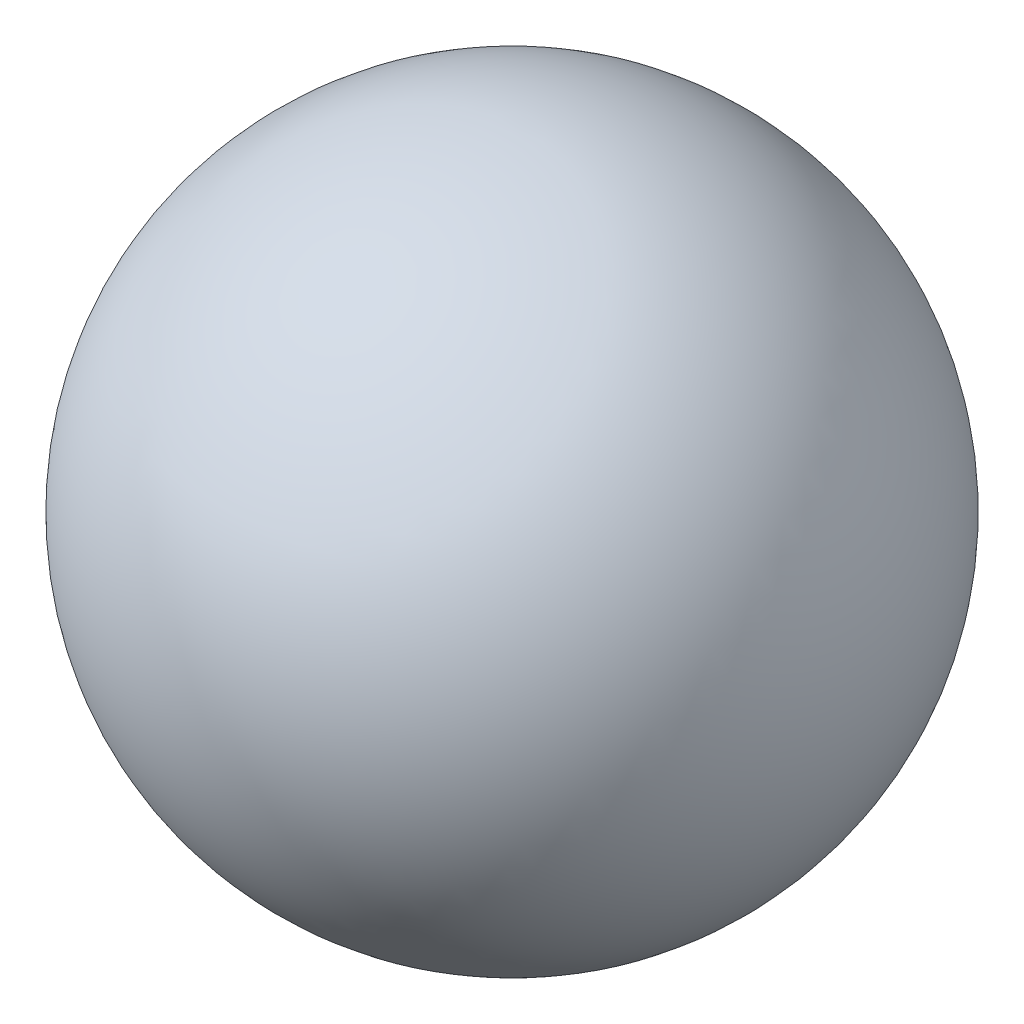
from build123d import *


with BuildPart() as part:
    # Sketch1 → Revolve1 (revolve)
    with BuildSketch(Plane.XY):
        with BuildLine():
            Line((0, 1), (0, -1))
            ThreePointArc((0, -1), (1, 0), (0, 1))
        make_face()
    revolve(axis=Axis((0, 1, 0), (0, -1, 0)))


solid = part.part
